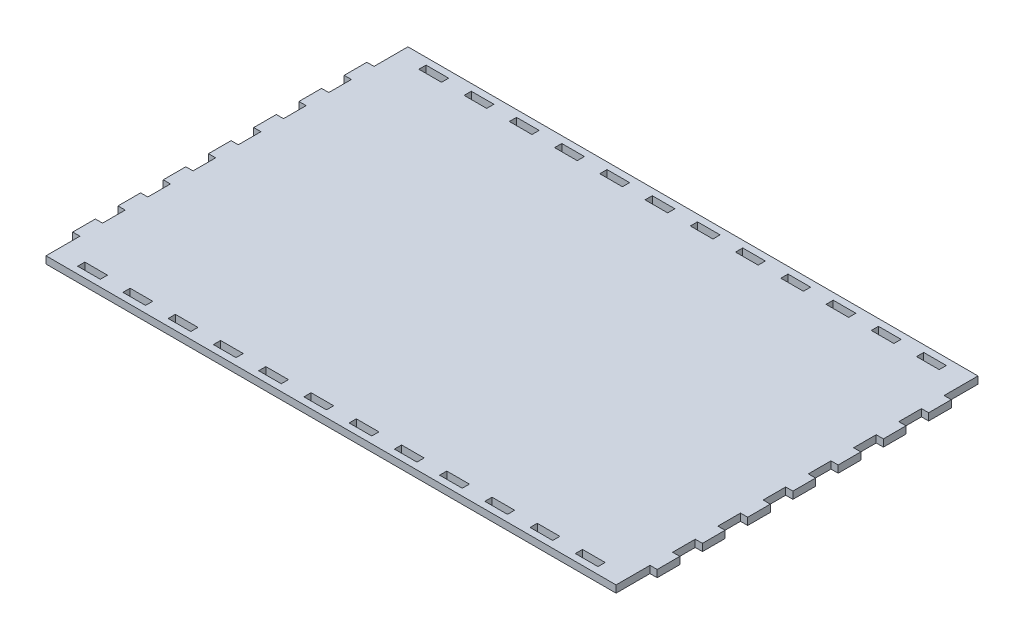
from build123d import *

# Parameters (mm, degrees)
SKETCH2_W           = 10
SKETCH2_H           = 3.175
BOSS_EXTRUDE1_DEPTH = 3.175


with BuildPart() as part:
    # Sketch2 → Boss-Extrude1 (new body)
    with BuildSketch(Plane(origin=(0, 0, 0), x_dir=(1, 0, 0), z_dir=(0, 1, 0))):
        Polygon((-137.685687371, 51.939525879), (-137.685687371, 66.939525879), (114.314312629, 66.939525879), (114.314312629, 51.939525879), (117.489312629, 51.939525879), (117.489312629, 41.939525879), (114.314312629, 41.939525879), (114.314312629, 31.939525879), (117.489312629, 31.939525879), (117.489312629, 21.939525879), (114.314312629, 21.939525879), (114.314312629, 11.939525879), (117.489312629, 11.939525879), (117.489312629, 1.939525879), (114.314312629, 1.939525879), (114.314312629, -8.060474121), (117.489312629, -8.060474121), (117.489312629, -18.060474121), (114.314312629, -18.060474121), (114.314312629, -28.060474121), (117.489312629, -28.060474121), (117.489312629, -38.060474121), (114.314312629, -38.060474121), (114.314312629, -48.060474121), (117.489312629, -48.060474121), (117.489312629, -58.060474121), (114.314312629, -58.060474121), (114.314312629, -68.060474121), (117.489312629, -68.060474121), (117.489312629, -78.060474121), (114.314312629, -78.060474121), (114.314312629, -93.060474121), (-137.685687371, -93.060474121), (-137.685687371, -78.060474121), (-140.860687371, -78.060474121), (-140.860687371, -68.060474121), (-137.685687371, -68.060474121), (-137.685687371, -58.060474121), (-140.860687371, -58.060474121), (-140.860687371, -48.060474121), (-137.685687371, -48.060474121), (-137.685687371, -38.060474121), (-140.860687371, -38.060474121), (-140.860687371, -28.060474121), (-137.685687371, -28.060474121), (-137.685687371, -18.060474121), (-140.860687371, -18.060474121), (-140.860687371, -8.060474121), (-137.685687371, -8.060474121), (-137.685687371, 1.939525879), (-140.860687371, 1.939525879), (-140.860687371, 11.939525879), (-137.685687371, 11.939525879), (-137.685687371, 21.939525879), (-140.860687371, 21.939525879), (-140.860687371, 31.939525879), (-137.685687371, 31.939525879), (-137.685687371, 41.939525879), (-140.860687371, 41.939525879), (-140.860687371, 51.939525879), align=None)
        with Locations((-101.685687371, 62.352025879)):
            Rectangle(SKETCH2_W, SKETCH2_H, mode=Mode.SUBTRACT)
        with Locations((-121.685687371, 62.352025879)):
            Rectangle(SKETCH2_W, SKETCH2_H, mode=Mode.SUBTRACT)
        with Locations((-81.685687371, 62.352025879)):
            Rectangle(SKETCH2_W, SKETCH2_H, mode=Mode.SUBTRACT)
        with Locations((-61.685687371, 62.352025879)):
            Rectangle(SKETCH2_W, SKETCH2_H, mode=Mode.SUBTRACT)
        with Locations((-41.685687371, 62.352025879)):
            Rectangle(SKETCH2_W, SKETCH2_H, mode=Mode.SUBTRACT)
        with Locations((-21.685687371, 62.352025879)):
            Rectangle(SKETCH2_W, SKETCH2_H, mode=Mode.SUBTRACT)
        with Locations((-1.685687371, 62.352025879)):
            Rectangle(SKETCH2_W, SKETCH2_H, mode=Mode.SUBTRACT)
        with Locations((18.314312629, 62.352025879)):
            Rectangle(SKETCH2_W, SKETCH2_H, mode=Mode.SUBTRACT)
        with Locations((38.314312629, 62.352025879)):
            Rectangle(SKETCH2_W, SKETCH2_H, mode=Mode.SUBTRACT)
        with Locations((58.314312629, 62.352025879)):
            Rectangle(SKETCH2_W, SKETCH2_H, mode=Mode.SUBTRACT)
        with Locations((78.314312629, 62.352025879)):
            Rectangle(SKETCH2_W, SKETCH2_H, mode=Mode.SUBTRACT)
        with Locations((98.314312629, 62.352025879)):
            Rectangle(SKETCH2_W, SKETCH2_H, mode=Mode.SUBTRACT)
        with Locations((98.314312629, -88.472974121)):
            Rectangle(SKETCH2_W, SKETCH2_H, mode=Mode.SUBTRACT)
        with Locations((78.314312629, -88.472974121)):
            Rectangle(SKETCH2_W, SKETCH2_H, mode=Mode.SUBTRACT)
        with Locations((58.314312629, -88.472974121)):
            Rectangle(SKETCH2_W, SKETCH2_H, mode=Mode.SUBTRACT)
        with Locations((38.314312629, -88.472974121)):
            Rectangle(SKETCH2_W, SKETCH2_H, mode=Mode.SUBTRACT)
        with Locations((18.314312629, -88.472974121)):
            Rectangle(SKETCH2_W, SKETCH2_H, mode=Mode.SUBTRACT)
        with Locations((-1.685687371, -88.472974121)):
            Rectangle(SKETCH2_W, SKETCH2_H, mode=Mode.SUBTRACT)
        with Locations((-21.685687371, -88.472974121)):
            Rectangle(SKETCH2_W, SKETCH2_H, mode=Mode.SUBTRACT)
        with Locations((-41.685687371, -88.472974121)):
            Rectangle(SKETCH2_W, SKETCH2_H, mode=Mode.SUBTRACT)
        with Locations((-61.685687371, -88.472974121)):
            Rectangle(SKETCH2_W, SKETCH2_H, mode=Mode.SUBTRACT)
        with Locations((-81.685687371, -88.472974121)):
            Rectangle(SKETCH2_W, SKETCH2_H, mode=Mode.SUBTRACT)
        with Locations((-101.685687371, -88.472974121)):
            Rectangle(SKETCH2_W, SKETCH2_H, mode=Mode.SUBTRACT)
        with Locations((-121.685687371, -88.472974121)):
            Rectangle(SKETCH2_W, SKETCH2_H, mode=Mode.SUBTRACT)
    extrude(amount=BOSS_EXTRUDE1_DEPTH)


solid = part.part
